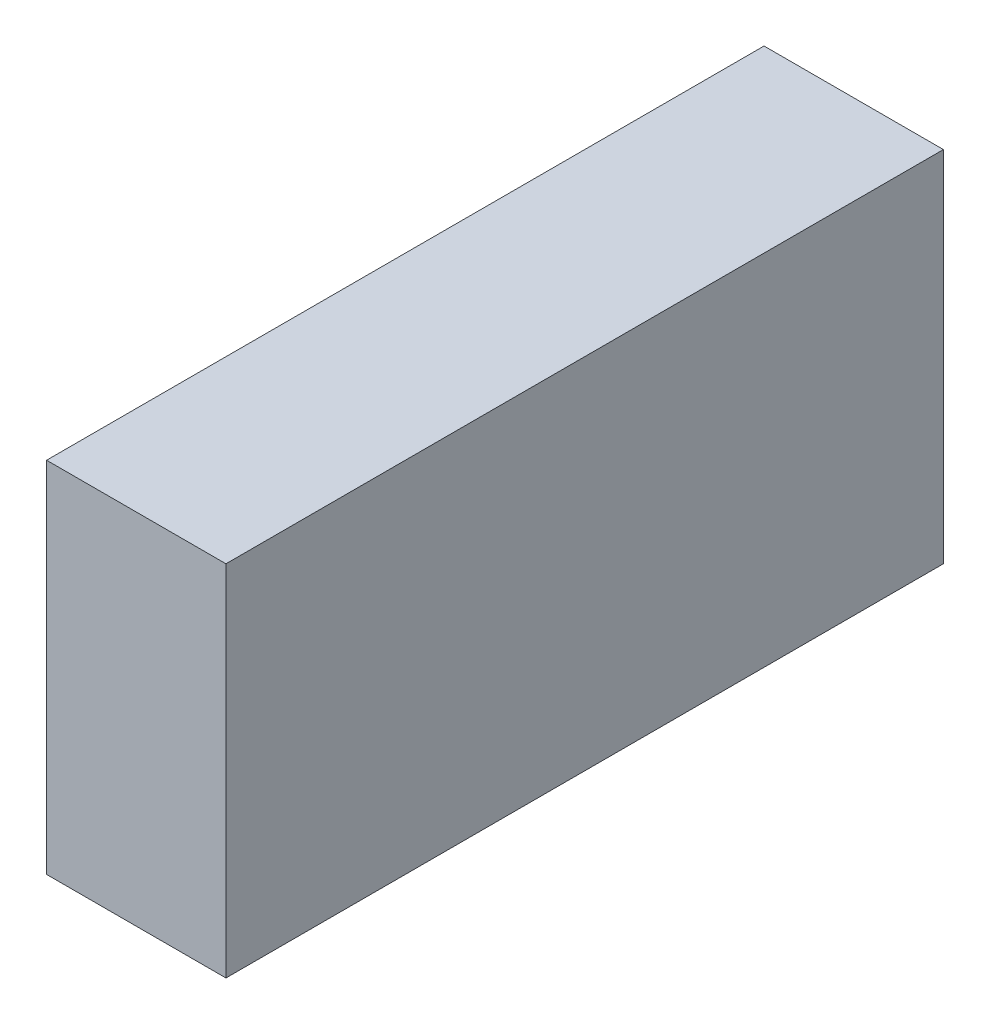
from build123d import *

# Parameters (mm, degrees)
SKETCH1_W      = 6.35
SKETCH1_H      = 3.175
EXTRUDE1_DEPTH = 0.79375


with BuildPart() as part:
    # Sketch1 → Extrude1 (new, symmetric)
    with BuildSketch(Plane(origin=(0, 0, 0), x_dir=(0, 0, -1), z_dir=(1, 0, 0))):
        Rectangle(SKETCH1_W, SKETCH1_H)
    extrude(amount=EXTRUDE1_DEPTH, both=True)


solid = part.part
